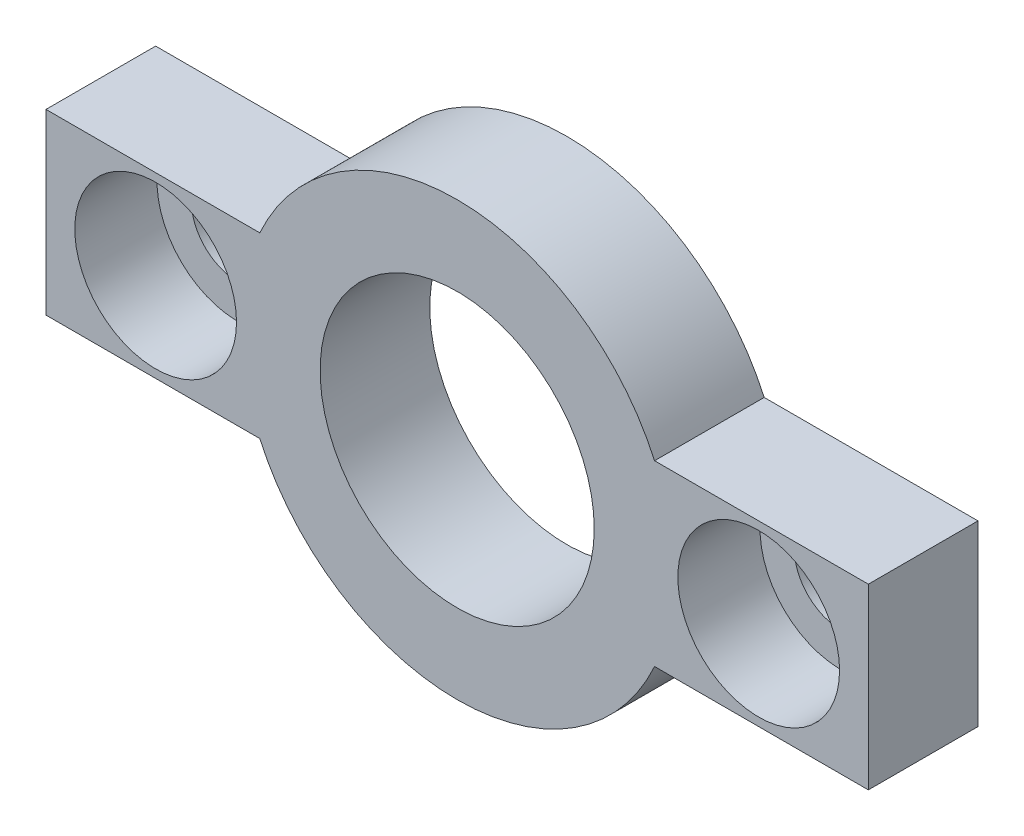
from build123d import *

# Parameters (mm, degrees)
CROQUIS1_R              = 5
SALIENTE_EXTRUIR1_DEPTH = 4
CROQUIS2_R              = 1.7
CORTAR_EXTRUIR1_DEPTH   = 4
CROQUIS3_R              = 2.95
CORTAR_EXTRUIR2_DEPTH   = 3


with BuildPart() as part:
    # Croquis1 → Saliente-Extruir1 (new body)
    with BuildSketch(Plane.XY):
        with BuildLine():
            Line((-7.200520814, 3.25), (-15, 3.25))
            Line((-15, 3.25), (-15, -3.25))
            Line((-15, -3.25), (-7.200520814, -3.25))
            ThreePointArc((-7.200520814, -3.25), (0, -7.9), (7.200520814, -3.25))
            Line((7.200520814, -3.25), (15, -3.25))
            Line((15, -3.25), (15, 3.25))
            Line((15, 3.25), (7.200520814, 3.25))
            ThreePointArc((7.200520814, 3.25), (0, 7.9), (-7.200520814, 3.25))
        make_face()
        Circle(CROQUIS1_R, mode=Mode.SUBTRACT)
    extrude(amount=SALIENTE_EXTRUIR1_DEPTH)

    # Croquis2 → Cortar-Extruir1 (cut)
    with BuildSketch(Plane.XY.offset(4)):
        with Locations((-11, 0)):
            Circle(CROQUIS2_R)
        with Locations((11, 0)):
            Circle(CROQUIS2_R)
    extrude(amount=-CORTAR_EXTRUIR1_DEPTH, mode=Mode.SUBTRACT)

    # Croquis3 → Cortar-Extruir2 (cut)
    with BuildSketch(Plane.XY.offset(4)):
        with Locations((-11, 0)):
            Circle(CROQUIS3_R)
        with Locations((11, 0)):
            Circle(CROQUIS3_R)
    extrude(amount=-CORTAR_EXTRUIR2_DEPTH, mode=Mode.SUBTRACT)


solid = part.part
